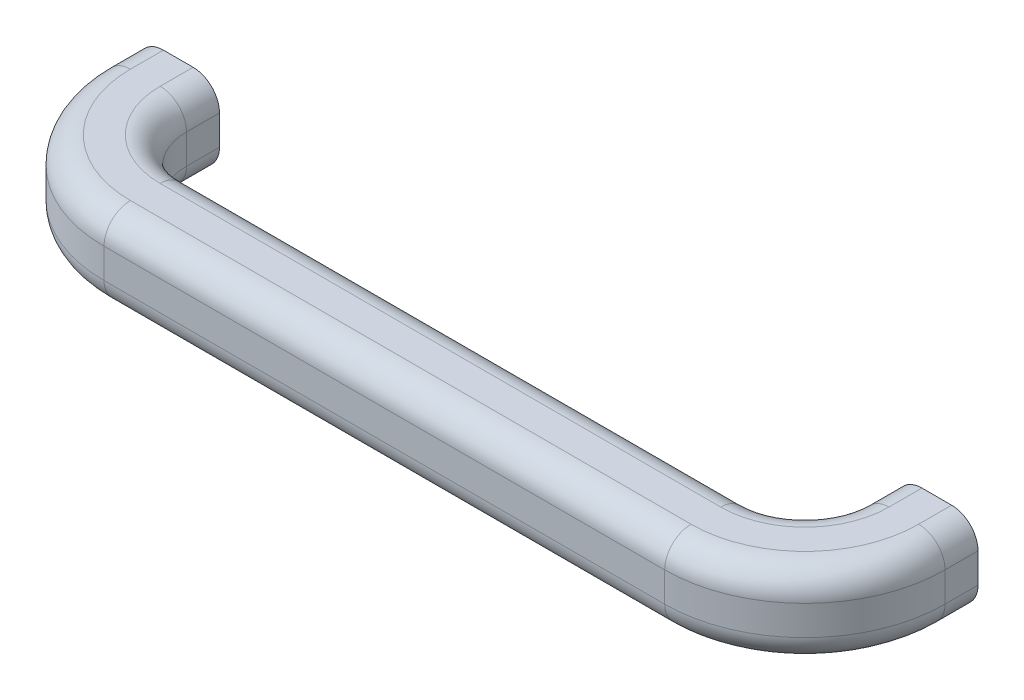
from build123d import *

# Parameters (mm, degrees)
SKETCH11_W         = 485.793761844
SKETCH11_H         = 595.960227968
CUT_EXTRUDE1_DEPTH = 130.789538956


with BuildPart() as part:
    # Sweep-Thin1: sweep along a path in Sketch2
    with BuildLine(Plane(origin=(0, 0, 0), x_dir=(1, 0, 0), z_dir=(0, 1, 0))) as sweep_thin1_path:
        Line((0, 169.789538956), (0, 157.289538956))
        Line((0, 157.289538956), (0, 30))
        ThreePointArc((0, 30), (-8.786796564, 8.786796564), (-30, 0))
        Line((-30, 0), (-200, 0))
        ThreePointArc((-200, 0), (-221.213203436, 8.786796564), (-230, 30))
        Line((-230, 30), (-230, 40))
    # Sketch6 → Sweep-Thin1 (sweep)
    with BuildSketch(Plane.XY.offset(-40)):
        with BuildLine():
            Line((-225.5, 12.5), (-234.5, 12.5))
            ThreePointArc((-234.5, 12.5), (-240.156854249, 10.156854249), (-242.5, 4.5))
            Line((-242.5, 4.5), (-242.5, -4.5))
            ThreePointArc((-242.5, -4.5), (-240.156854249, -10.156854249), (-234.5, -12.5))
            Line((-234.5, -12.5), (-225.5, -12.5))
            ThreePointArc((-225.5, -12.5), (-219.843145751, -10.156854249), (-217.5, -4.5))
            Line((-217.5, -4.5), (-217.5, 4.5))
            ThreePointArc((-217.5, 4.5), (-219.843145751, 10.156854249), (-225.5, 12.5))
        make_face()
        with BuildLine():
            Line((-225.5, 9.5), (-234.5, 9.5))
            ThreePointArc((-234.5, 9.5), (-238.035533906, 8.035533906), (-239.5, 4.5))
            Line((-239.5, 4.5), (-239.5, -4.5))
            ThreePointArc((-239.5, -4.5), (-238.035533906, -8.035533906), (-234.5, -9.5))
            Line((-234.5, -9.5), (-225.5, -9.5))
            ThreePointArc((-225.5, -9.5), (-221.964466094, -8.035533906), (-220.5, -4.5))
            Line((-220.5, -4.5), (-220.5, 4.5))
            ThreePointArc((-220.5, 4.5), (-221.964466094, 8.035533906), (-225.5, 9.5))
        make_face(mode=Mode.SUBTRACT)
    sweep(path=sweep_thin1_path.line)

    # Sketch11 → Cut-Extrude1 (cut, through all)
    with BuildSketch(Plane.XY.offset(-40)):
        with Locations((212.093031721, 3.359547151)):
            Rectangle(SKETCH11_W, SKETCH11_H)
    extrude(amount=-CUT_EXTRUDE1_DEPTH, mode=Mode.SUBTRACT)


solid = part.part
